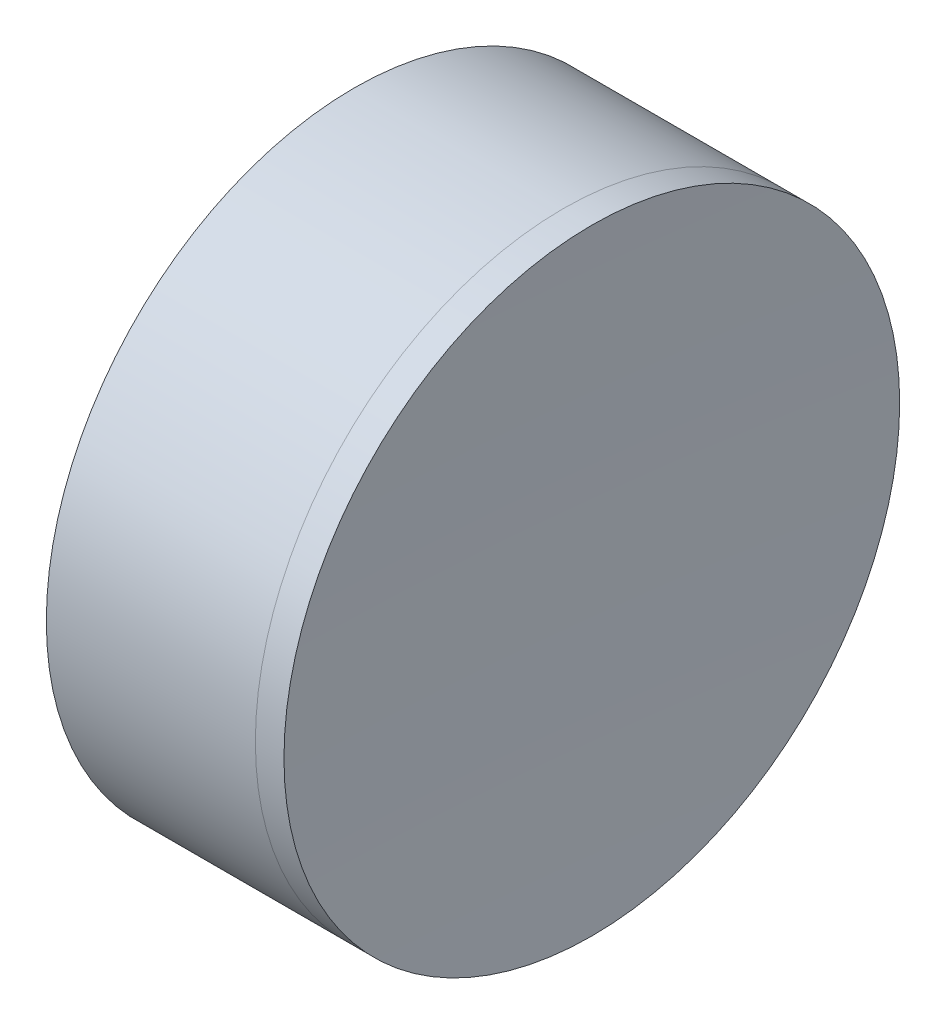
from build123d import *


with BuildPart() as part:
    # 草图1 one side → 旋转1 (revolve)
    with BuildSketch(Plane(origin=(0, 0, 0), x_dir=(1, 0, 0), z_dir=(0, 1, 0)), mode=Mode.PRIVATE) as revolve_1_sk:
        with BuildLine():
            Line((161.541823758, 12.7), (152.918264236, 12.7))
            ThreePointArc((152.918264236, 12.7), (155.571823894, 6.594834211), (156.478791315, 0))
            Line((156.478791315, 0), (158.478791315, 0))
            ThreePointArc((158.478791315, 0), (159.255372807, 6.532077919), (161.541823758, 12.7))
        make_face()
    revolve(revolve_1_sk.sketch.rotate(Axis((-185.274474051, 0, 0), (1, 0, 0)), 180), axis=Axis((-185.274474051, 0, 0), (1, 0, 0)))  # turned: the seam where the file's is


with BuildPart() as body_2:
    # 草图2 one side → 旋转3 (revolve)
    with BuildSketch(Plane(origin=(0, 0, 0), x_dir=(1, 0, 0), z_dir=(0, 1, 0)), mode=Mode.PRIVATE) as revolve_3_sk:
        with BuildLine():
            Line((162.721567331, 12.7), (161.541823758, 12.7))
            ThreePointArc((161.541823758, 12.7), (159.255372807, 6.532077919), (158.478791315, 0))
            Line((158.478791315, 0), (162.478791315, 0))
            ThreePointArc((162.478791315, 0), (162.539490862, 6.351160134), (162.721567331, 12.7))
        make_face()
    revolve(revolve_3_sk.sketch.rotate(Axis((152.918264236, 0, 0), (1, 0, 0)), 180), axis=Axis((152.918264236, 0, 0), (1, 0, 0)))  # turned: the seam where the file's is


solid = Compound([part.part, body_2.part])
